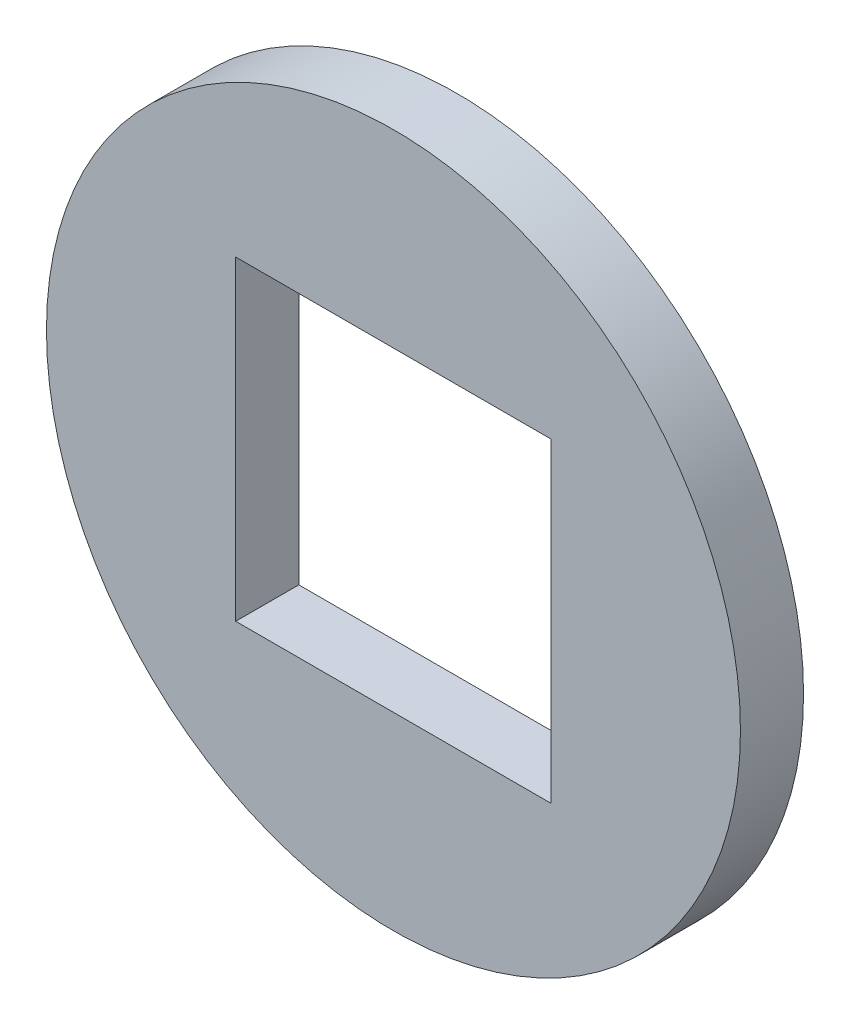
from build123d import *

# Parameters (mm, degrees)
SKETCH1_R           = 11
SKETCH1_W           = 10
SKETCH1_H           = 10
BOSS_EXTRUDE1_DEPTH = 2


with BuildPart() as part:
    # Sketch1 → Boss-Extrude1 (new body)
    with BuildSketch(Plane.XY):
        Circle(SKETCH1_R)
        Rectangle(SKETCH1_W, SKETCH1_H, mode=Mode.SUBTRACT)
    extrude(amount=BOSS_EXTRUDE1_DEPTH)


solid = part.part
